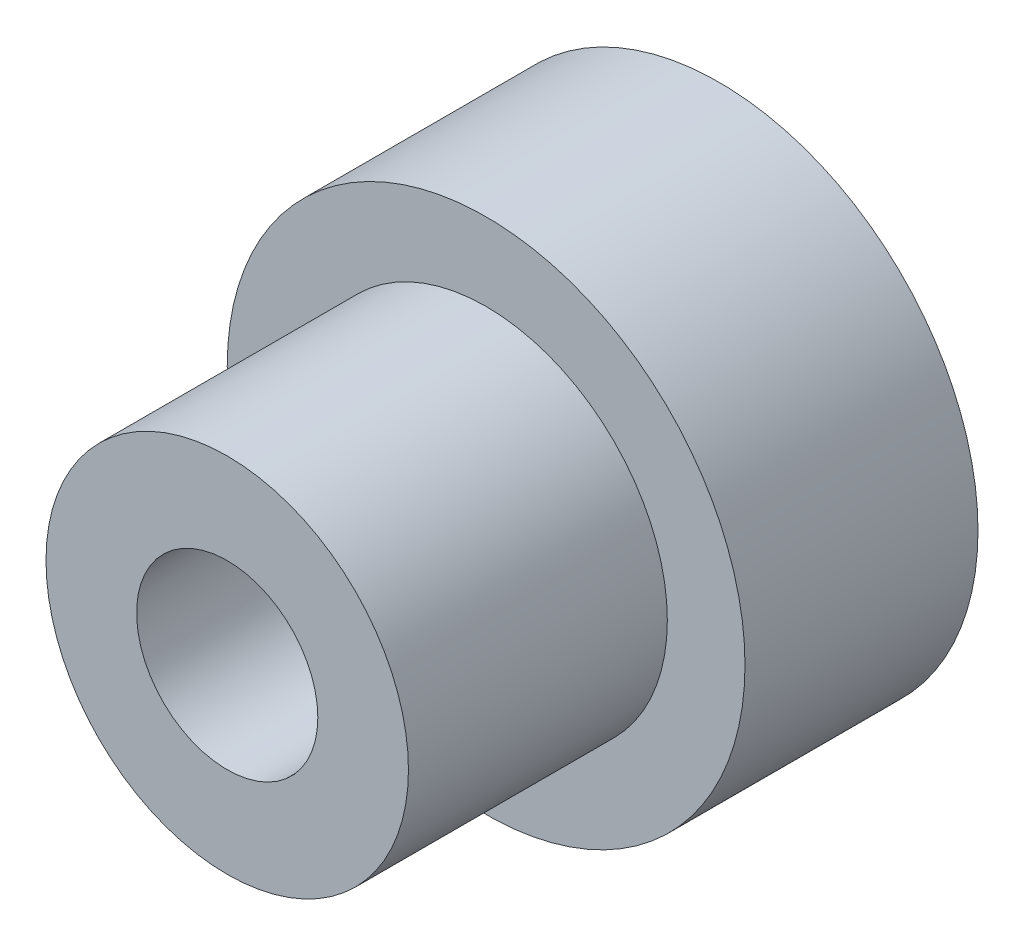
from build123d import *

# Parameters (mm, degrees)
SKETCH_2_R          = 7
EXTRUDE_1_DEPTH     = 10
SKETCH_3_R          = 10
EXTRUDE_2_DEPTH     = 9
SKETCH_4_R          = 3.5
CUT_EXTRUDE_1_DEPTH = 20
CUT_EXTRUDE_START   = -13
SKETCH_5_R          = 5.5
CUT_EXTRUDE_2_DEPTH = 2.5


with BuildPart() as part:
    # Эскиз2 → Бобышка-Вытянуть1 (new body)
    with BuildSketch(Plane.XY):
        Circle(SKETCH_2_R)
    extrude(amount=EXTRUDE_1_DEPTH)

    # Эскиз3 → Бобышка-Вытянуть2 (add)
    with BuildSketch(Plane(origin=(0, 0, 0), x_dir=(-1, 0, 0), z_dir=(0, 0, -1))):
        Circle(SKETCH_3_R)
    extrude(amount=EXTRUDE_2_DEPTH)

    # Эскиз4 → Вырез-Вытянуть1 (cut, through all)
    with BuildSketch(Plane.XY.offset(10)):
        Circle(SKETCH_4_R)
    extrude(amount=-CUT_EXTRUDE_1_DEPTH, mode=Mode.SUBTRACT)

    # Эскиз5 → Вырез-Вытянуть2 (cut)
    with BuildSketch(Plane.XY.offset(10).offset(CUT_EXTRUDE_START)):
        Circle(SKETCH_5_R)
    extrude(amount=-CUT_EXTRUDE_2_DEPTH, mode=Mode.SUBTRACT)


solid = part.part
